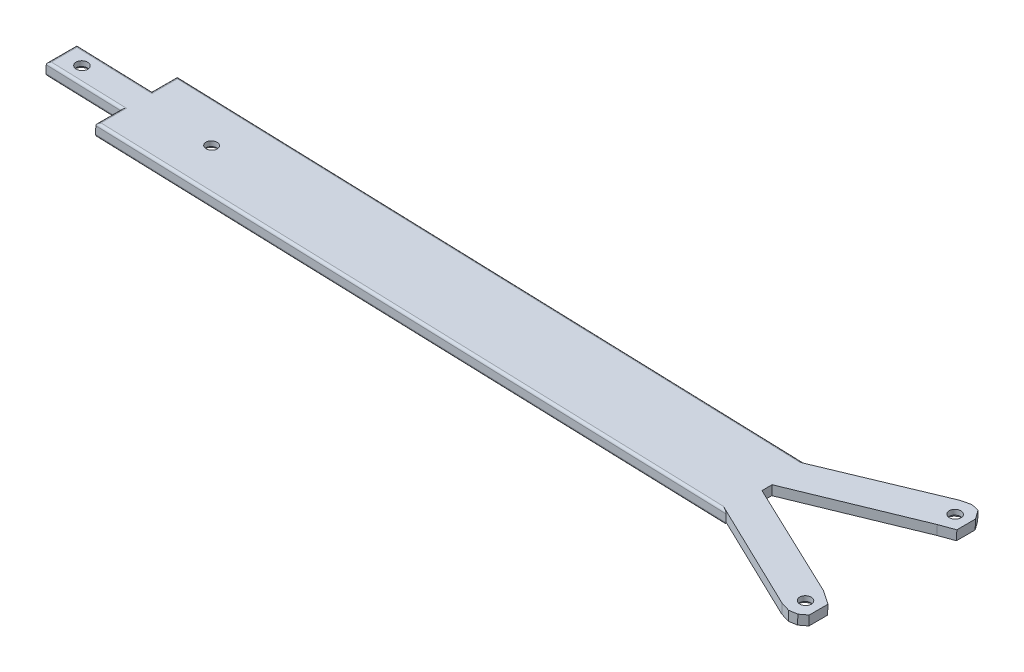
from build123d import *

# Parameters (mm, degrees)
SKETCH1_R           = 1.15
SKETCH1_R_2         = 1.1
BOSS_EXTRUDE1_DEPTH = 2.5
SKETCH2_R           = 2.1
CUT_EXTRUDE1_DEPTH  = 1.5
SKETCH3_W           = 95.504738846
SKETCH3_H           = 6
BOSS_EXTRUDE2_DEPTH = 1.5
FILLET1_R           = 0.5
FILLET2_R           = 0.5
SKETCH4_R           = 2.1
SKETCH4_W           = 96.504738846
SKETCH4_H           = 7
CUT_EXTRUDE2_DEPTH  = 0.6


with BuildPart() as part:
    # Sketch1 → Boss-Extrude1 (new body)
    with BuildSketch(Plane(origin=(0.142209029, 4.250598455, 0), x_dir=(0.999440809, -0.033437529, 0), z_dir=(-0.033437529, -0.999440809, 0))):
        Polygon((11.443429389, 116.200036636), (14.167398509, 118.020989552), (14.167398349, 121.688114552), (12.943429389, 122.700036636), (11.443429389, 123.000036636), (9.639575481, 122.500036636), (-10.832601571, 113.00003089), (-134.806739216, 113.00003089), (-134.806739216, 108.000029776), (-149.556569968, 108.000029776), (-149.556569968, 102.000029776), (-134.806740003, 102.000029776), (-134.806740003, 97.00003089), (-10.832601571, 97.00003089), (9.643430674, 87.500036636), (11.443430674, 87.000036636), (12.943429388, 87.300036636), (14.167399777, 89.020989552), (14.167399616, 92.688114552), (11.443430674, 93.800036636), (-10.832601571, 104.00003089), (-10.832601571, 106.00003089), align=None)
        with Locations((11.443429389, 119.700036636)):
            Circle(SKETCH1_R, mode=Mode.SUBTRACT)
        with Locations((11.443430674, 90.300036636)):
            Circle(SKETCH1_R, mode=Mode.SUBTRACT)
        with Locations((-145.556569968, 105.000029776)):
            Circle(SKETCH1_R, mode=Mode.SUBTRACT)
        with Locations((-120.056569968, 105.00003089)):
            Circle(SKETCH1_R_2, mode=Mode.SUBTRACT)
    extrude(amount=BOSS_EXTRUDE1_DEPTH)

    # Sketch2 → Cut-Extrude1 (cut)
    with BuildSketch(Plane(origin=(0.058615208, 1.751996431, 0), x_dir=(0.999440809, -0.033437529, 0), z_dir=(-0.033437529, -0.999440809, 0))):
        with Locations((-145.556569968, 105.000029776)):
            Circle(SKETCH2_R)
        with Locations((-120.056569968, 105.00003089)):
            Circle(SKETCH2_R)
        with Locations((11.443429389, 119.700036636)):
            Circle(SKETCH2_R)
        with Locations((11.443430674, 90.300036636)):
            Circle(SKETCH2_R)
    extrude(amount=-CUT_EXTRUDE1_DEPTH, mode=Mode.SUBTRACT)

    # Sketch3 → Boss-Extrude2 (add)
    with BuildSketch(Plane(origin=(0.058615208, 1.751996431, 0), x_dir=(0.999440809, -0.033437529, 0), z_dir=(-0.033437529, -0.999440809, 0))):
        with Locations((-66.082119318, 105.00003089)):
            Rectangle(SKETCH3_W, SKETCH3_H)
    extrude(amount=BOSS_EXTRUDE2_DEPTH)

    # Fillet1
    fillet1_edges = [part.edges().sort_by_distance(p)[0] for p in [
        (-113.712218368, 5.558340404, 105.00003089),
        (-65.986551616, 3.961619186, 102.00003089),
        (-18.260884865, 2.364897967, 105.00003089),
        (-65.986551616, 3.961619186, 108.00003089),
        (-113.762374661, 4.05917919, 105.00003089),
        (-66.036707909, 2.462457971, 102.00003089),
        (-18.311041158, 0.865736753, 105.00003089),
        (-66.036707909, 2.462457971, 108.00003089),
    ]]
    fillet(fillet1_edges, radius=FILLET1_R)

    # Fillet2
    fillet2_edges = [part.edges().sort_by_distance(p)[0] for p in [
        (-72.636741689, 6.685508279, 97.00003089),
        (-134.589148324, 8.758202679, 99.500030333),
        (-141.959939325, 9.00480161, 102.000029776),
        (-149.330730325, 9.25140054, 105.000029776),
        (-141.959938931, 9.004801596, 108.000029776),
        (-134.589147538, 8.758202653, 110.500030333),
        (-72.636741296, 6.685508266, 113.00003089),
        (-72.720335117, 4.186906242, 113.00003089),
        (-134.672741359, 6.259600629, 110.500030333),
        (-142.043532753, 6.506199573, 108.000029776),
        (-149.414324146, 6.752798517, 105.000029776),
        (-142.043533146, 6.506199586, 102.000029776),
        (-134.672742146, 6.259600655, 99.500030333),
        (-72.72033551, 4.186906256, 97.00003089),
    ]]
    fillet(fillet2_edges, radius=FILLET2_R)

    # Sketch4 → Cut-Extrude2 (cut)
    with BuildSketch(Plane(origin=(0.058615208, 1.751996431, 0), x_dir=(0.999440809, -0.033437529, 0), z_dir=(-0.033437529, -0.999440809, 0))):
        Polygon((11.443429389, 116.200036636), (14.167398509, 118.020989552), (14.167398349, 121.688114552), (12.943429389, 122.700036636), (11.443429389, 123.000036636), (9.639575481, 122.500036636), (-10.832601571, 113.00003089), (-11.910083922, 112.50003089), (-134.306739216, 112.50003089), (-134.306739216, 107.500029776), (-149.056569968, 107.500029776), (-149.056569968, 102.500029776), (-134.306740003, 102.500029776), (-134.306740003, 97.50003089), (-11.91028813, 97.50003089), (-10.832601571, 97.00003089), (9.643430674, 87.500036636), (11.443430674, 87.000036636), (12.943429388, 87.300036636), (14.167399777, 89.020989552), (14.167399616, 92.688114552), (11.443430674, 93.800036636), (-10.832601571, 104.00003089), (-10.832601571, 106.00003089), align=None)
        with Locations((11.443430674, 90.300036636)):
            Circle(SKETCH4_R, mode=Mode.SUBTRACT)
        with Locations((-145.556569968, 105.000029776)):
            Circle(SKETCH4_R, mode=Mode.SUBTRACT)
        with Locations((-120.056569968, 105.00003089)):
            Circle(SKETCH4_R, mode=Mode.SUBTRACT)
        with Locations((-66.082119318, 105.00003089)):
            Rectangle(SKETCH4_W, SKETCH4_H, mode=Mode.SUBTRACT)
        with Locations((11.443429389, 119.700036636)):
            Circle(SKETCH4_R, mode=Mode.SUBTRACT)
    extrude(amount=-CUT_EXTRUDE2_DEPTH, mode=Mode.SUBTRACT)


solid = part.part
